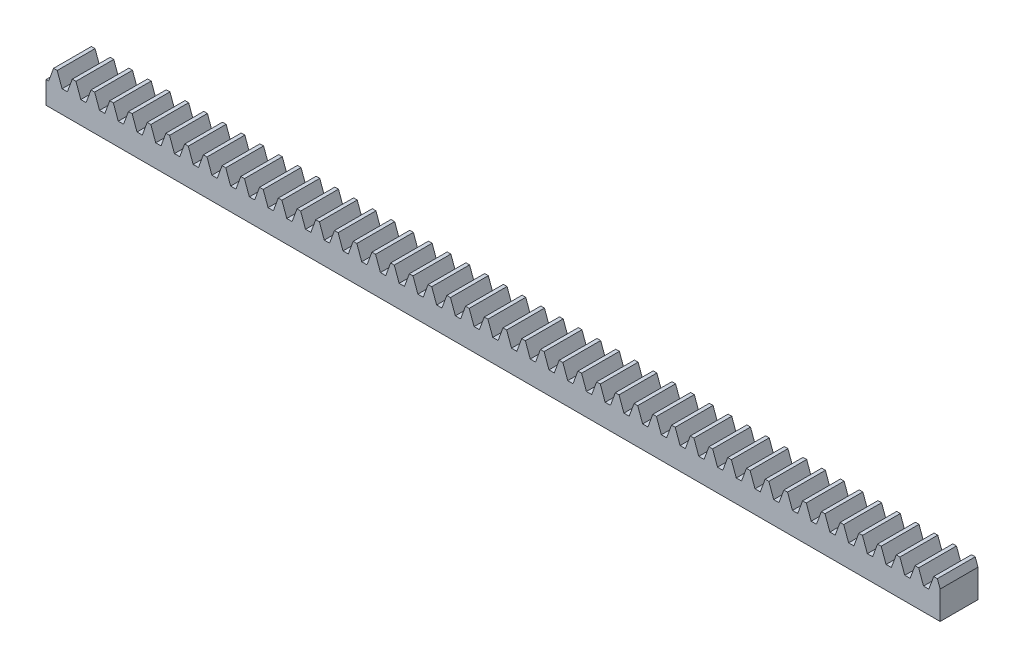
from build123d import *

# Parameters (mm, degrees)
BLANKSKE_W        = 150
BLANKSKE_H        = 6
BLANK_DEPTH       = 6.35
TOOTHCUTSIM_DEPTH = 151.254192953
TEETHCUTS_COUNT   = 49
TEETHCUTS_PITCH   = 3.14159265


with BuildPart() as part:
    # BlankSke → Blank (new body)
    with BuildSketch(Plane.XY):
        with Locations((75, 3)):
            Rectangle(BLANKSKE_W, BLANKSKE_H)
    extrude(amount=-BLANK_DEPTH)

    # TooCutSkeSim → ToothCutSim (cut, through all)
    with BuildSketch(Plane.XY):
        Polygon((0.44443537, 3.75), (-0.44443537, 3.75), (-1.272613241, 6.0254), (1.272613241, 6.0254), align=None)
    toothcutsim = extrude(amount=-TOOTHCUTSIM_DEPTH, mode=Mode.SUBTRACT)

    # TeethCuts: ToothCutSim ×49
    with Locations(*[(i * TEETHCUTS_PITCH, 0, 0) for i in range(1, TEETHCUTS_COUNT)]):
        add(toothcutsim, mode=Mode.SUBTRACT)


solid = part.part
